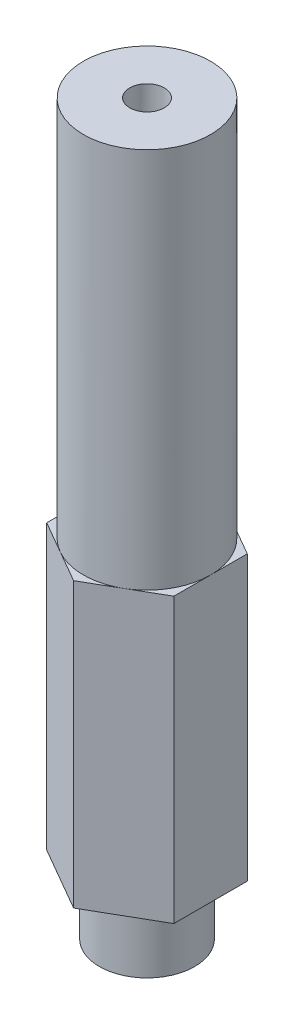
from build123d import *

# Parameters (mm, degrees)
BOSS_EXTRUDE1_DEPTH       = 28.321
SKETCH2_R                 = 4.7625
BOSS_EXTRUDE2_DEPTH       = 6.35
SKETCH3_R                 = 6.35
BOSS_EXTRUDE3_DEPTH       = 38.1
F_8_32_TAPPED_HOLE1_D     = 3.4544
F_8_32_TAPPED_HOLE1_DEPTH = 10.668
F_8_32_TAPPED_HOLE1_TIP   = 1.037806461
SKETCH7_R                 = 3.175
CUT_EXTRUDE2_DEPTH        = 6.35


with BuildPart() as part:
    # Sketch1 → Boss-Extrude1 (new body)
    with BuildSketch(Plane(origin=(0, 0, 0), x_dir=(1, 0, 0), z_dir=(0, 1, 0))):
        Polygon((6.35, -3.666174209), (6.35, 3.666174209), (0, 7.332348419), (-6.35, 3.666174209), (-6.35, -3.666174209), (0, -7.332348419), align=None)
    extrude(amount=BOSS_EXTRUDE1_DEPTH)

    # Sketch2 → Boss-Extrude2 (add)
    with BuildSketch(Plane.XZ):
        Circle(SKETCH2_R)
    extrude(amount=BOSS_EXTRUDE2_DEPTH)

    # Sketch3 → Boss-Extrude3 (add)
    with BuildSketch(Plane(origin=(0, 28.321, 0), x_dir=(1, 0, 0), z_dir=(0, 1, 0))):
        Circle(SKETCH3_R)
    extrude(amount=BOSS_EXTRUDE3_DEPTH)

    # 8-32 Tapped Hole1
    with Locations(Plane(origin=(0, 66.421, 0), x_dir=(1, 0, 0), z_dir=(0, 1, 0))):
        with Locations((0, 0)):
            Hole(F_8_32_TAPPED_HOLE1_D / 2, depth=F_8_32_TAPPED_HOLE1_DEPTH)
            with Locations((0, 0, -(F_8_32_TAPPED_HOLE1_DEPTH + F_8_32_TAPPED_HOLE1_TIP / 2))):  # 118° drill point
                Cone(0, F_8_32_TAPPED_HOLE1_D / 2, F_8_32_TAPPED_HOLE1_TIP, mode=Mode.SUBTRACT)

    # Sketch7 → Cut-Extrude2 (cut)
    with BuildSketch(Plane.XZ.offset(6.35)):
        Circle(SKETCH7_R)
    extrude(amount=-CUT_EXTRUDE2_DEPTH, mode=Mode.SUBTRACT)


solid = part.part
